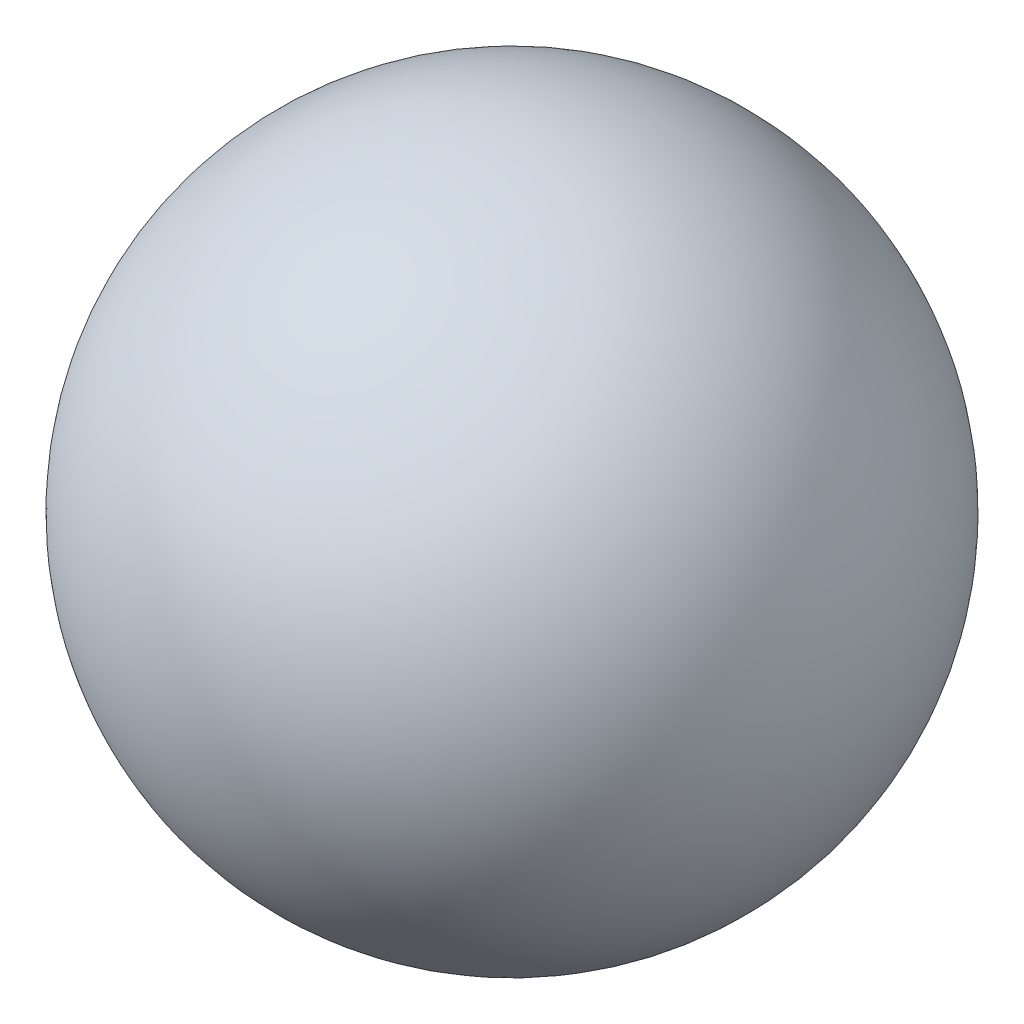
from build123d import *


with BuildPart() as part:
    # Sketch1 → Revolve1 (revolve)
    with BuildSketch(Plane(origin=(0, 0, 0), x_dir=(1, 0, 0), z_dir=(0, 1, 0))):
        with BuildLine():
            Line((0, 0), (0, -177.8))
            ThreePointArc((0, -177.8), (-88.9, -88.9), (0, 0))
        make_face()
    revolve(axis=Axis((0, 0, 0), (0, 0, 1)))


solid = part.part
